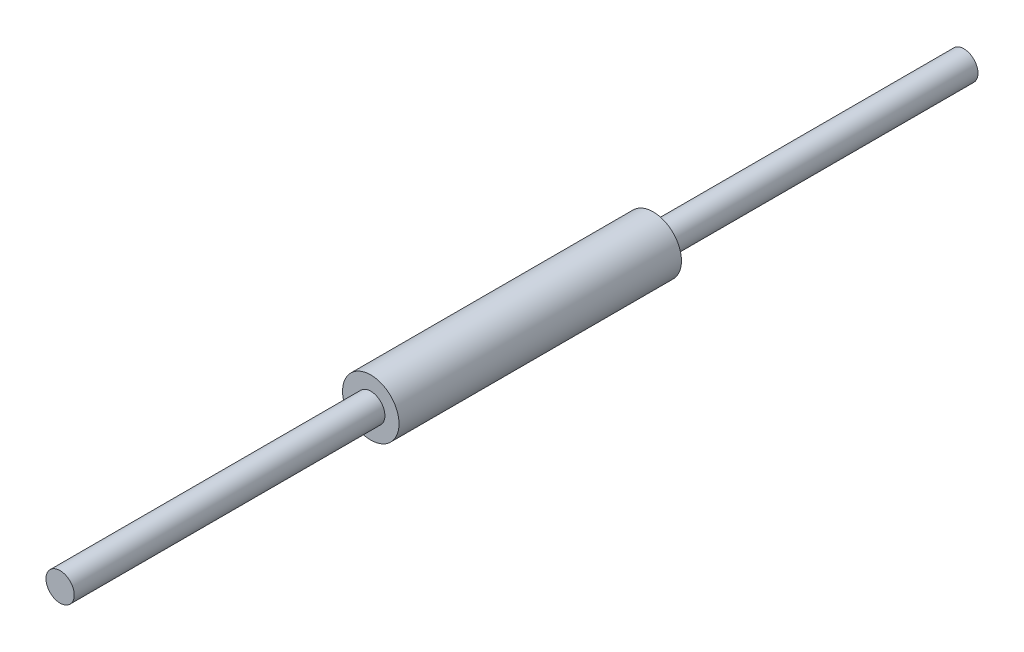
from build123d import *

# Parameters (mm, degrees)
SKETCH2_R           = 25
BOSS_EXTRUDE1_DEPTH = 125
SKETCH4_R           = 12.5
BOSS_EXTRUDE2_DEPTH = 400


with BuildPart() as part:
    # Sketch2 → Boss-Extrude1 (new body, symmetric)
    with BuildSketch(Plane.XY):
        Circle(SKETCH2_R)
    extrude(amount=BOSS_EXTRUDE1_DEPTH, both=True)

    # Sketch4 → Boss-Extrude2 (add, symmetric)
    with BuildSketch(Plane.XY):
        Circle(SKETCH4_R)
    extrude(amount=BOSS_EXTRUDE2_DEPTH, both=True)


solid = part.part
